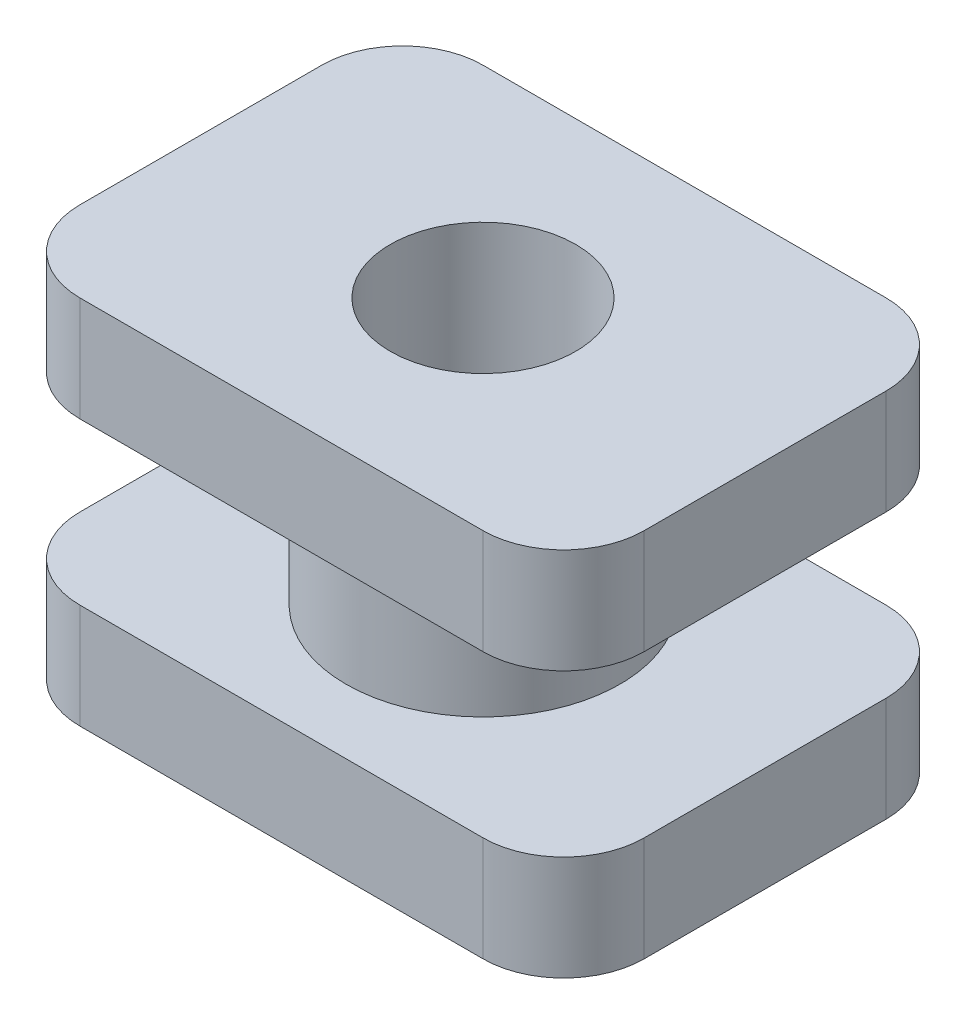
from build123d import *

# Parameters (mm, degrees)
SKETCH1_R           = 2.159
BOSS_EXTRUDE1_DEPTH = 2.54
SKETCH2_W           = 8.89
SKETCH2_H           = 6.35
BOSS_EXTRUDE2_DEPTH = 1.651
SKETCH3_W           = 8.89
SKETCH3_H           = 6.35
BOSS_EXTRUDE3_DEPTH = 1.651
SKETCH4_R           = 1.4605
CUT_EXTRUDE1_DEPTH  = 6.842
FILLET1_R           = 1.27


with BuildPart() as part:
    # Sketch1 → Boss-Extrude1 (new body)
    with BuildSketch(Plane(origin=(0, 0, 0), x_dir=(1, 0, 0), z_dir=(0, 1, 0))):
        Circle(SKETCH1_R)
    extrude(amount=BOSS_EXTRUDE1_DEPTH)

    # Sketch2 → Boss-Extrude2 (add)
    with BuildSketch(Plane(origin=(0, 2.54, 0), x_dir=(1, 0, 0), z_dir=(0, 1, 0))):
        Rectangle(SKETCH2_W, SKETCH2_H)
    extrude(amount=BOSS_EXTRUDE2_DEPTH)

    # Sketch3 → Boss-Extrude3 (add)
    with BuildSketch(Plane(origin=(0, 0, 0), x_dir=(-1, 0, 0), z_dir=(0, -1, 0))):
        Rectangle(SKETCH3_W, SKETCH3_H)
    extrude(amount=BOSS_EXTRUDE3_DEPTH)

    # Sketch4 → Cut-Extrude1 (cut, through all)
    with BuildSketch(Plane(origin=(0, 4.191, 0), x_dir=(1, 0, 0), z_dir=(0, 1, 0))):
        Circle(SKETCH4_R)
    extrude(amount=-CUT_EXTRUDE1_DEPTH, mode=Mode.SUBTRACT)

    # Fillet1
    fillet1_edges = [part.edges().sort_by_distance(p)[0] for p in [
        (-4.445, -0.8255, 3.175),
        (-4.445, -0.8255, -3.175),
        (4.445, -0.8255, -3.175),
        (4.445, -0.8255, 3.175),
        (4.445, 3.3655, 3.175),
        (4.445, 3.3655, -3.175),
        (-4.445, 3.3655, -3.175),
        (-4.445, 3.3655, 3.175),
    ]]
    fillet(fillet1_edges, radius=FILLET1_R)


solid = part.part
